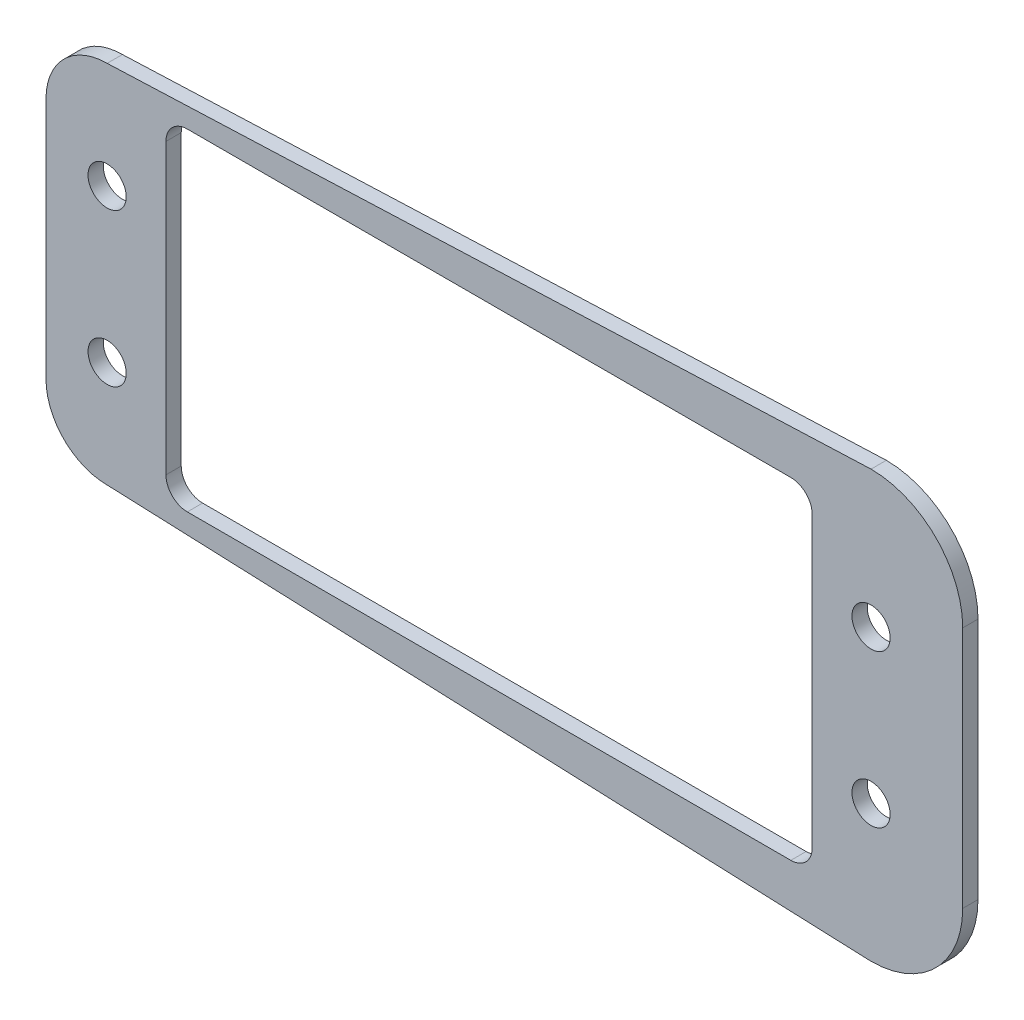
from build123d import *

# Parameters (mm, degrees)
SKETCH_1_R      = 1.25
EXTRUDE_1_DEPTH = 1


with BuildPart() as part:
    # 草图1 → 凸台-拉伸1 (new body)
    with BuildSketch(Plane.XY):
        with BuildLine():
            Line((41, -7.95), (41, 7.95))
            ThreePointArc((41, 7.95), (39.242640687, 12.192640687), (35, 13.95))
            Line((35, 13.95), (-15, 11.95))
            ThreePointArc((-15, 11.95), (-17.828427125, 10.778427125), (-19, 7.95))
            Line((-19, 7.95), (-19, -7.95))
            ThreePointArc((-19, -7.95), (-17.828427125, -10.778427125), (-15, -11.95))
            Line((-15, -11.95), (35, -13.95))
            ThreePointArc((35, -13.95), (39.242640687, -12.192640687), (41, -7.95))
        make_face()
        with Locations((35, -5)):
            Circle(SKETCH_1_R, mode=Mode.SUBTRACT)
        with Locations((35, 5)):
            Circle(SKETCH_1_R, mode=Mode.SUBTRACT)
        with Locations((-15, -5)):
            Circle(SKETCH_1_R, mode=Mode.SUBTRACT)
        with Locations((-15, 5)):
            Circle(SKETCH_1_R, mode=Mode.SUBTRACT)
        with BuildLine():
            Line((29.75, 10.85), (-9.75, 10.85))
            ThreePointArc((-9.75, 10.85), (-10.739949494, 10.439949494), (-11.15, 9.45))
            Line((-11.15, 9.45), (-11.15, -9.45))
            ThreePointArc((-11.15, -9.45), (-10.739949494, -10.439949494), (-9.75, -10.85))
            Line((-9.75, -10.85), (29.75, -10.85))
            ThreePointArc((29.75, -10.85), (30.739949494, -10.439949494), (31.15, -9.45))
            Line((31.15, -9.45), (31.15, 9.45))
            ThreePointArc((31.15, 9.45), (30.739949494, 10.439949494), (29.75, 10.85))
        make_face(mode=Mode.SUBTRACT)
    extrude(amount=EXTRUDE_1_DEPTH)


solid = part.part
